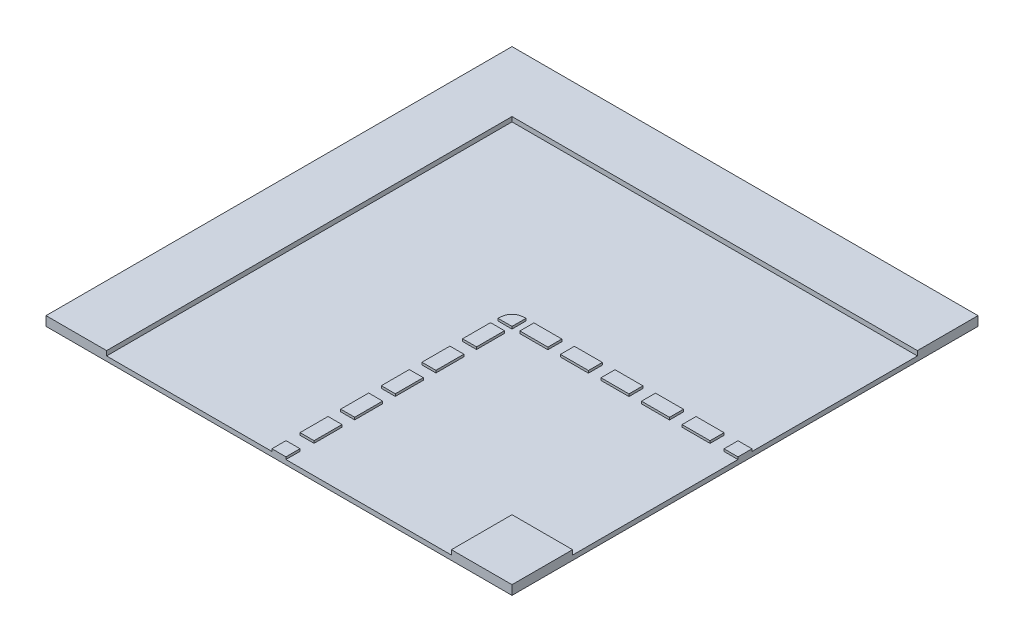
from build123d import *

# Parameters (mm, degrees)
ESBO_O1_W                = 1
ESBO_O1_H                = 1
RESSALTO_EXTRUS_O1_DEPTH = 0.01
ESBO_O2_W                = 0.13
ESBO_O2_H                = 0.13
RESSALTO_EXTRUS_O2_DEPTH = 0.02
ESBO_O3_W                = 0.03
ESBO_O3_H                = 0.030215991
ESBO_O3_H_2              = 0.06
ESBO_O3_H_3              = 0.03
ESBO_O3_W_2              = 0.06
RESSALTO_EXTRUS_O4_DEPTH = 0.005


with BuildPart() as part:
    # Esboço1 → Ressalto-extrusão1 (new body)
    with BuildSketch(Plane(origin=(0, 0, 0), x_dir=(1, 0, 0), z_dir=(0, 1, 0))):
        Rectangle(ESBO_O1_W, ESBO_O1_H)
    extrude(amount=RESSALTO_EXTRUS_O1_DEPTH)

    # Esboço2 → Ressalto-extrusão2 (add)
    with BuildSketch(Plane(origin=(0, 0, 0), x_dir=(1, 0, 0), z_dir=(0, 1, 0))):
        Polygon((0.5, 0.5), (-0.5, 0.5), (-0.5, -0.5), (-0.37, -0.5), (-0.37, 0.37), (0.5, 0.37), align=None)
        with Locations((0.435, -0.435)):
            Rectangle(ESBO_O2_W, ESBO_O2_H)
    extrude(amount=RESSALTO_EXTRUS_O2_DEPTH)

    # Esboço3 → Ressalto-extrusão4 (add)
    with BuildSketch(Plane(origin=(0, 0.01, 0), x_dir=(1, 0, 0), z_dir=(0, 1, 0))):
        with Locations((-0.000170216, -0.484892793)):
            Rectangle(ESBO_O3_W, ESBO_O3_H)
        with Locations((0, -0.409784797)):
            Rectangle(ESBO_O3_W, ESBO_O3_H_2)
        with BuildLine():
            Line((-0.015, -0.015), (0.015, -0.015))
            Line((0.015, -0.015), (0.015, 0.015))
            add(Edge.make_bspline(
                [(-0.015, -0.015), (-0.015, 0.015), (0.015, 0.015)],
                knots=[0, 0, 0, 1, 1, 1], degree=2))
        make_face()
        with Locations((0.485, 0)):
            Rectangle(ESBO_O3_W, ESBO_O3_H_3)
        with Locations((0.32298751, 0)):
            Rectangle(ESBO_O3_W_2, ESBO_O3_H_3)
        with Locations((0.41, 0)):
            Rectangle(ESBO_O3_W_2, ESBO_O3_H_3)
        with Locations((0.235975021, 0)):
            Rectangle(ESBO_O3_W_2, ESBO_O3_H_3)
        with Locations((0.148962531, 0)):
            Rectangle(ESBO_O3_W_2, ESBO_O3_H_3)
        with Locations((0.061950042, 0)):
            Rectangle(ESBO_O3_W_2, ESBO_O3_H_3)
        with Locations((0, -0.322610574)):
            Rectangle(ESBO_O3_W, ESBO_O3_H_2)
        with Locations((0, -0.235436351)):
            Rectangle(ESBO_O3_W, ESBO_O3_H_2)
        with Locations((0, -0.148262129)):
            Rectangle(ESBO_O3_W, ESBO_O3_H_2)
        with Locations((0, -0.061087906)):
            Rectangle(ESBO_O3_W, ESBO_O3_H_2)
    extrude(amount=RESSALTO_EXTRUS_O4_DEPTH)


solid = part.part
